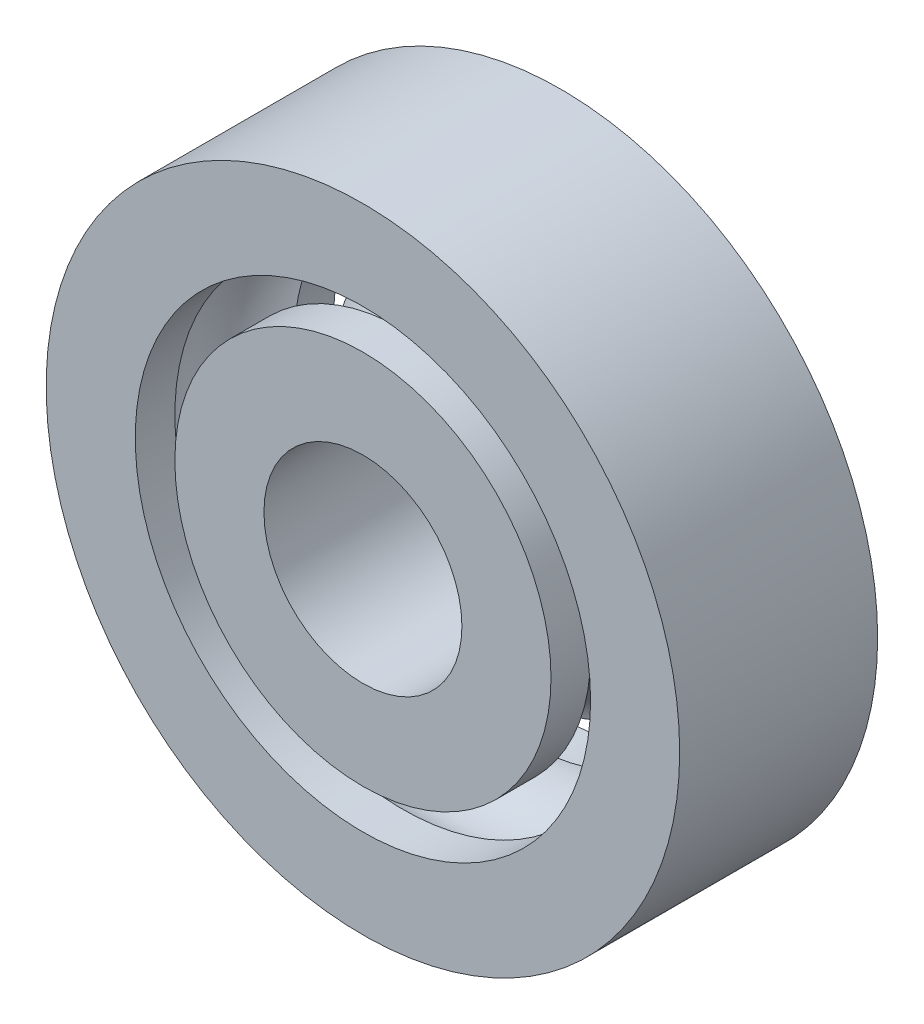
from build123d import *


with BuildPart() as part:
    # Sketch3 → Revolve1 (revolve)
    with BuildSketch(Plane(origin=(0, 0, 0), x_dir=(0, 0, -1), z_dir=(1, 0, 0))):
        with BuildLine():
            ThreePointArc((-1.5, 4.75), (0, 3.66886117), (1.5, 4.75))
            Line((1.5, 4.75), (2.5, 4.75))
            Line((2.5, 4.75), (2.5, 2.5))
            Line((2.5, 2.5), (-2.5, 2.5))
            Line((-2.5, 2.5), (-2.5, 4.75))
            Line((-2.5, 4.75), (-1.5, 4.75))
        make_face()
        with BuildLine():
            Line((-2.5, 5.75), (-1.5, 5.75))
            ThreePointArc((-1.5, 5.75), (0, 6.83113883), (1.5, 5.75))
            Line((1.5, 5.75), (2.5, 5.75))
            Line((2.5, 5.75), (2.5, 8))
            Line((2.5, 8), (-2.5, 8))
            Line((-2.5, 8), (-2.5, 5.75))
        make_face()
    revolve(axis=Axis((0, 0, 2.5), (0, 0, -1)))


solid = part.part
